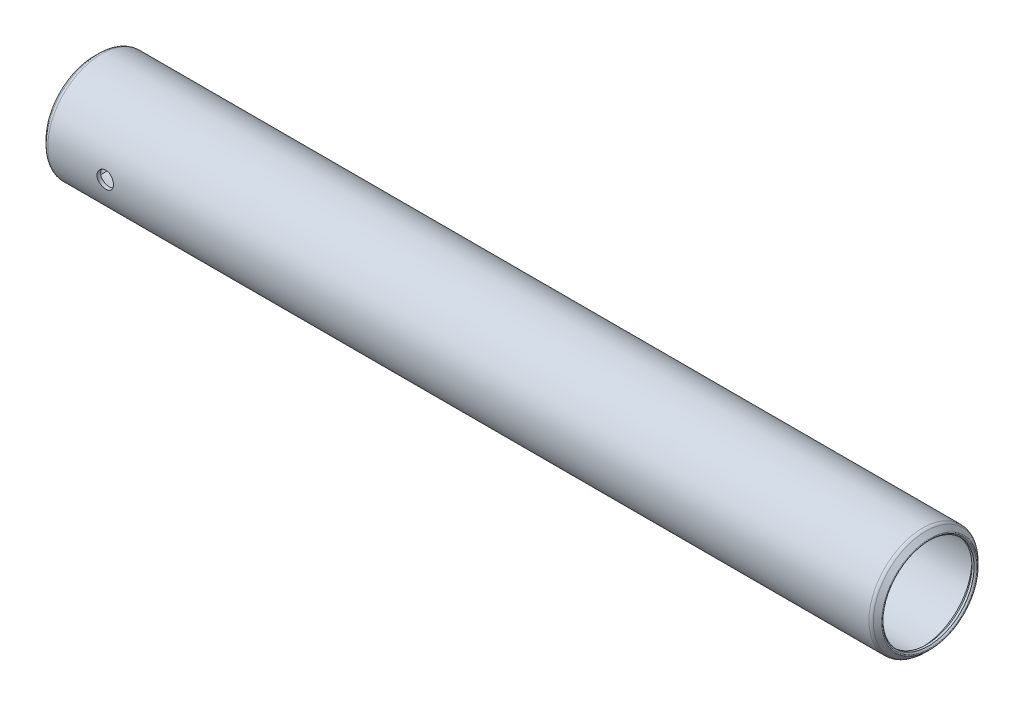
from build123d import *

# Parameters (mm, degrees)
SKETCH2_R          = 1.1938
CUT_EXTRUDE1_DEPTH = 7.8105


with BuildPart() as part:
    # Sketch1 → Revolve1 (revolve)
    with BuildSketch(Plane.XY):
        with BuildLine():
            Line((-0.517960245, 6.836210245), (-0.3175, 6.63575))
            Line((-0.3175, 6.63575), (0, 6.63575))
            Line((0, 6.63575), (0.635, 7.27075))
            Line((0.635, 7.27075), (119.9134, 7.27075))
            Line((119.9134, 7.27075), (120.5484, 6.63575))
            Line((120.5484, 6.63575), (120.8659, 6.63575))
            Line((120.8659, 6.63575), (121.066360245, 6.836210245))
            ThreePointArc((121.066360245, 6.836210245), (121.103557684, 6.926012806), (121.066360245, 7.015815367))
            Line((121.066360245, 7.015815367), (120.457662806, 7.624512806))
            ThreePointArc((120.457662806, 7.624512806), (120.25165398, 7.762163503), (120.00865, 7.8105))
            Line((120.00865, 7.8105), (0.53975, 7.8105))
            ThreePointArc((0.53975, 7.8105), (0.29674602, 7.762163503), (0.090737194, 7.624512806))
            Line((0.090737194, 7.624512806), (-0.517960245, 7.015815367))
            ThreePointArc((-0.517960245, 7.015815367), (-0.555157684, 6.926012806), (-0.517960245, 6.836210245))
        make_face()
    revolve(axis=Axis((120.5484, 0, 0), (-1, 0, 0)))

    # Sketch2 → Cut-Extrude1 (cut)
    with BuildSketch(Plane.XY):
        with Locations((8.89, 0)):
            Circle(SKETCH2_R)
    extrude(amount=CUT_EXTRUDE1_DEPTH, mode=Mode.SUBTRACT)


solid = part.part
